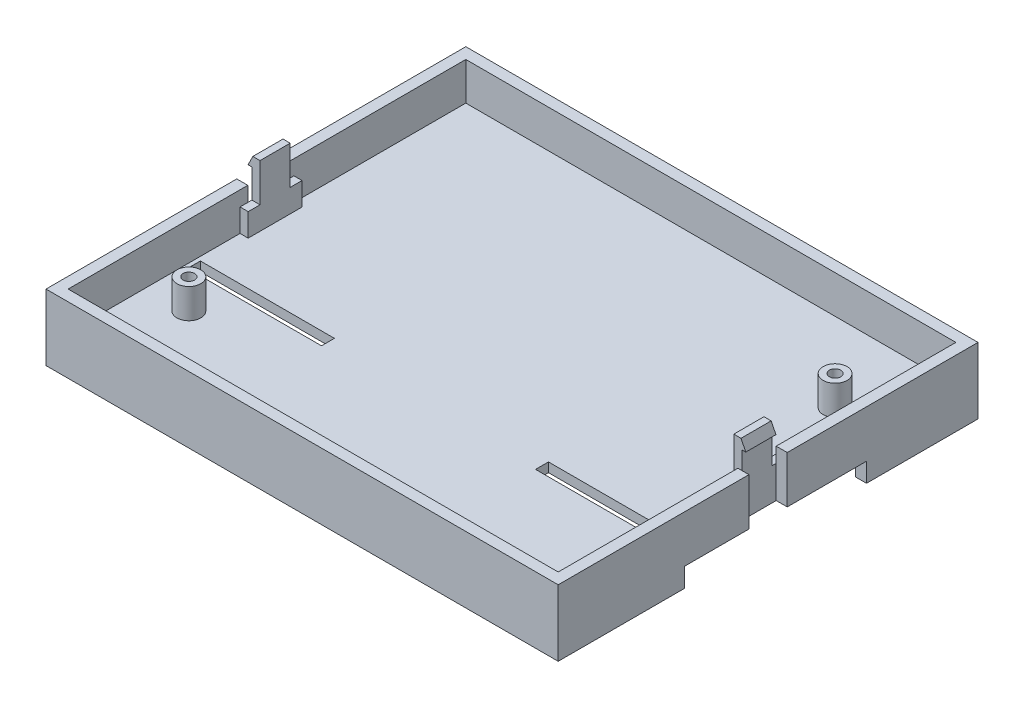
from build123d import *

# Parameters (mm, degrees)
SKETCH1_W           = 107
SKETCH1_H           = 87.7
BOSS_EXTRUDE1_DEPTH = 13.85
SKETCH2_W           = 102.38
SKETCH2_H           = 83.08
CUT_EXTRUDE1_DEPTH  = 7.9
CUT_EXTRUDE2_DEPTH  = 4
SKETCH4_R           = 2.5
SKETCH4_R_2         = 1.2
BOSS_EXTRUDE2_DEPTH = 6.2
SKETCH5_W           = 28
SKETCH5_H           = 2.7
CUT_EXTRUDE3_DEPTH  = 3.5
CHAMFER1_SIZE       = 2
SKETCH6_W           = 8
SKETCH6_H           = 9.85
CUT_EXTRUDE4_DEPTH  = 2.31
SKETCH7_W           = 11.25
SKETCH7_H           = 4.8
BOSS_EXTRUDE3_DEPTH = 1.7
BOSS_EXTRUDE4_DEPTH = 3.15


with BuildPart() as part:
    # Sketch1 → Boss-Extrude1 (new body)
    with BuildSketch(Plane(origin=(0, 0, 0), x_dir=(1, 0, 0), z_dir=(0, 1, 0))):
        Rectangle(SKETCH1_W, SKETCH1_H)
    extrude(amount=BOSS_EXTRUDE1_DEPTH)

    # Sketch2 → Cut-Extrude1 (cut)
    with BuildSketch(Plane(origin=(0, 13.85, 0), x_dir=(1, 0, 0), z_dir=(0, 1, 0))):
        Rectangle(SKETCH2_W, SKETCH2_H)
    extrude(amount=-CUT_EXTRUDE1_DEPTH, mode=Mode.SUBTRACT)

    # Sketch3 → Cut-Extrude2 (cut)
    with BuildSketch(Plane.XZ):
        Polygon((-51.19, 41.54), (51.19, 41.54), (51.19, 19.24), (23.5, 19.24), (23.5, 14.74), (49.4, 14.74), (49.4, 17.44), (53.5, 17.44), (53.5, -20.56), (51.19, -20.56), (51.19, -41.54), (10.19, -41.54), (10.19, -22.86), (40.69, -22.86), (42.704360061, -23.54), (43.44, -21.360818071), (41.067741267, -20.56), (6.19, -20.56), (6.19, -43.85), (-6.19, -43.85), (-6.19, -20.56), (-41.067741267, -20.56), (-43.44, -21.360818071), (-42.704360061, -23.54), (-40.69, -22.86), (-10.19, -22.86), (-10.19, -41.54), (-51.19, -41.54), (-51.19, -20.56), (-53.5, -20.56), (-53.5, 17.44), (-49.4, 17.44), (-49.4, 14.74), (-23.5, 14.74), (-23.5, 19.24), (-51.19, 19.24), align=None)
    extrude(amount=-CUT_EXTRUDE2_DEPTH, mode=Mode.SUBTRACT)

    # Sketch4 → Boss-Extrude2 (add)
    with BuildSketch(Plane(origin=(0, 5.95, 0), x_dir=(1, 0, 0), z_dir=(0, 1, 0))):
        with Locations((-42.5, -25)):
            Circle(SKETCH4_R)
        with Locations((-42.5, -25)):
            Circle(SKETCH4_R_2, mode=Mode.SUBTRACT)
        with Locations((42.5, 25)):
            Circle(SKETCH4_R)
        with Locations((42.5, 25)):
            Circle(SKETCH4_R_2, mode=Mode.SUBTRACT)
    extrude(amount=BOSS_EXTRUDE2_DEPTH)

    # Sketch5 → Cut-Extrude3 (cut)
    with BuildSketch(Plane(origin=(0, 5.95, 0), x_dir=(1, 0, 0), z_dir=(0, 1, 0))):
        with Locations((-36.36, -16.09)):
            Rectangle(SKETCH5_W, SKETCH5_H)
        with Locations((36.36, -16.09)):
            Rectangle(SKETCH5_W, SKETCH5_H)
    extrude(amount=-CUT_EXTRUDE3_DEPTH, mode=Mode.SUBTRACT)

    # Chamfer1
    chamfer1_edges = [part.edges().sort_by_distance(p)[0] for p in [
        (-36.45, 2.45, 14.74),
        (36.45, 2.45, 14.74),
    ]]
    chamfer(chamfer1_edges, length=CHAMFER1_SIZE)

    # Sketch6 → Cut-Extrude4 (cut)
    with BuildSketch(Plane.ZY.offset(53.5)):
        with Locations((0, 8.925)):
            Rectangle(SKETCH6_W, SKETCH6_H)
    cut_extrude4 = extrude(amount=-CUT_EXTRUDE4_DEPTH, mode=Mode.SUBTRACT)

    # Sketch7 → Boss-Extrude3 (add)
    with BuildSketch(Plane(origin=(-51.19, 0, 0), x_dir=(0, 0, -1), z_dir=(1, 0, 0))):
        with Locations((0, 8.35)):
            Rectangle(SKETCH7_W, SKETCH7_H)
    boss_extrude3 = extrude(amount=BOSS_EXTRUDE3_DEPTH)

    # Sketch8 → Boss-Extrude4 (add, symmetric)
    with BuildSketch(Plane.XY):
        Polygon((-49.49, 10.75), (-49.49, 18.75), (-50.99, 18.75), (-51.99, 16.75), (-51.19, 16.75), (-51.19, 10.75), align=None)
    boss_extrude4 = extrude(amount=BOSS_EXTRUDE4_DEPTH, both=True)

    # Mirror1: Cut-Extrude4, Boss-Extrude3, Boss-Extrude4 across plane
    add(cut_extrude4.mirror(Plane(origin=(0, 0, 0), x_dir=(0, 0, 1), z_dir=(1, 0, 0))), mode=Mode.SUBTRACT)
    add(boss_extrude3.mirror(Plane(origin=(0, 0, 0), x_dir=(0, 0, 1), z_dir=(1, 0, 0))))
    add(boss_extrude4.mirror(Plane(origin=(0, 0, 0), x_dir=(0, 0, 1), z_dir=(1, 0, 0))))


solid = part.part
